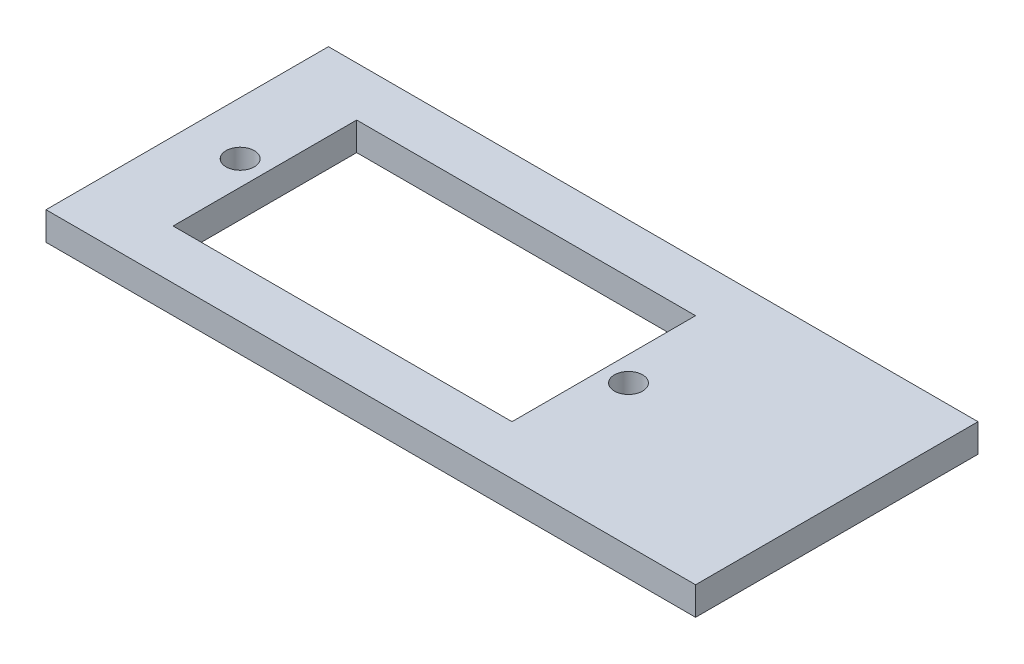
from build123d import *

# Parameters (mm, degrees)
SKICA1_W                 = 46
SKICA1_H                 = 20
P_IDAT_VYSUNUT_M1_DEPTH  = 2
SKICA2_W                 = 24
SKICA2_H                 = 13
ODEBRAT_VYSUNUT_M1_DEPTH = 2
SKICA3_R                 = 1
ODEBRAT_VYSUNUT_M2_DEPTH = 2


with BuildPart() as part:
    # Skica1 → Přidat vysunutím1 (new body)
    with BuildSketch(Plane(origin=(0, 0, 0), x_dir=(1, 0, 0), z_dir=(0, 1, 0))):
        Rectangle(SKICA1_W, SKICA1_H)
    extrude(amount=P_IDAT_VYSUNUT_M1_DEPTH)

    # Skica2 → Odebrat vysunutím1 (cut)
    with BuildSketch(Plane(origin=(0, 2, 0), x_dir=(1, 0, 0), z_dir=(0, 1, 0))):
        with Locations((-5.5, 0)):
            Rectangle(SKICA2_W, SKICA2_H)
    extrude(amount=-ODEBRAT_VYSUNUT_M1_DEPTH, mode=Mode.SUBTRACT)

    # Skica3 → Odebrat vysunutím2 (cut)
    with BuildSketch(Plane(origin=(0, 2, 0), x_dir=(1, 0, 0), z_dir=(0, 1, 0))):
        with Locations((-19.25, 0)):
            Circle(SKICA3_R)
        with Locations((8.25, 0)):
            Circle(SKICA3_R)
    extrude(amount=-ODEBRAT_VYSUNUT_M2_DEPTH, mode=Mode.SUBTRACT)


solid = part.part
